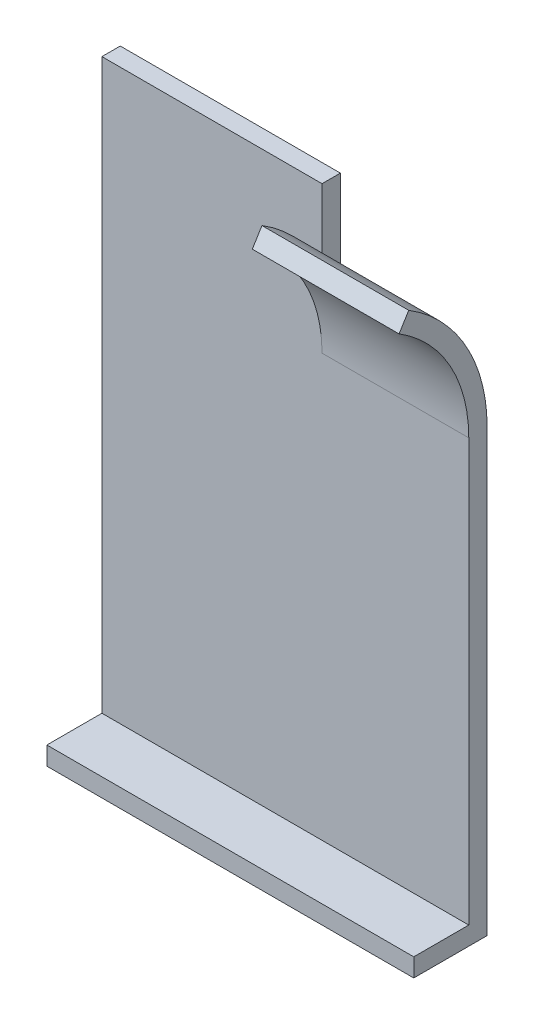
from build123d import *

# Parameters (mm, degrees)
BOSS_EXTRUDE1_DEPTH = 3.175
BOSS_EXTRUDE2_DEPTH = 25.4
SKETCH4_W           = 12.7
SKETCH4_H           = 3.175
BOSS_EXTRUDE3_DEPTH = 63.5


with BuildPart() as part:
    # Sketch1 → Boss-Extrude1 (new body)
    with BuildSketch(Plane.XY):
        Polygon((0, 101.6), (38.1, 101.6), (38.1, 76.2), (63.5, 76.2), (63.5, 0), (0, 0), align=None)
    extrude(amount=BOSS_EXTRUDE1_DEPTH)

    # Sketch2 → Boss-Extrude2 (add)
    with BuildSketch(Plane(origin=(63.5, 0, 0), x_dir=(0, 0, -1), z_dir=(1, 0, 0))):
        with BuildLine():
            Line((-3.175, 76.2), (0, 76.2))
            ThreePointArc((0, 76.2), (-3.62295396, 90.12573242), (-13.573125, 100.520246123))
            Line((-13.573125, 100.520246123), (-15.24, 97.817996554))
            ThreePointArc((-15.24, 97.817996554), (-6.39540352, 88.578428818), (-3.175, 76.2))
        make_face()
    extrude(amount=-BOSS_EXTRUDE2_DEPTH)

    # Sketch4 → Boss-Extrude3 (add)
    with BuildSketch(Plane(origin=(63.5, 0, 0), x_dir=(0, 0, -1), z_dir=(1, 0, 0))):
        with Locations((-6.35, 1.5875)):
            Rectangle(SKETCH4_W, SKETCH4_H)
    extrude(amount=-BOSS_EXTRUDE3_DEPTH)


solid = part.part
